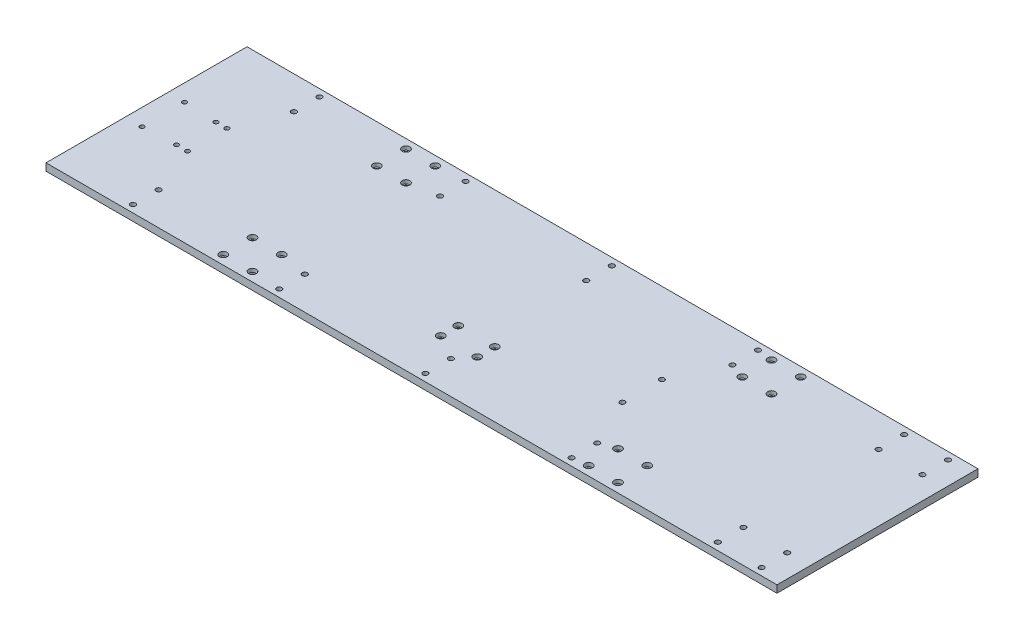
from build123d import *

# Parameters (mm, degrees)
SKETCH_1_W          = 1000
SKETCH_1_H          = 275
SKETCH_1_R          = 3
SKETCH_1_R_2        = 3.5
SKETCH_1_R_3        = 3.2
EXTRUDE_1_DEPTH     = 10
SKETCH_1290_R       = 5.25
CUT_EXTRUDE_1_DEPTH = 5


with BuildPart() as part:
    # Эскиз1 → Бобышка-Вытянуть1 (new body)
    with BuildSketch(Plane(origin=(0, 0, 0), x_dir=(1, 0, 0), z_dir=(0, 1, 0))):
        with Locations((223.202614379, 6.290849673)):
            Rectangle(SKETCH_1_W, SKETCH_1_H)
        with Locations((-253.797385621, 35.290849673)):
            Circle(SKETCH_1_R, mode=Mode.SUBTRACT)
        with Locations((-208.797385621, 33.290849673)):
            Circle(SKETCH_1_R, mode=Mode.SUBTRACT)
        with Locations((-193.797385621, 33.290849673)):
            Circle(SKETCH_1_R, mode=Mode.SUBTRACT)
        with Locations((-167.797385621, 133.790849673)):
            Circle(SKETCH_1_R_2, mode=Mode.SUBTRACT)
        with Locations((32.202614379, 133.790849673)):
            Circle(SKETCH_1_R_2, mode=Mode.SUBTRACT)
        with Locations((232.202614379, 133.790849673)):
            Circle(SKETCH_1_R_2, mode=Mode.SUBTRACT)
        with Locations((432.202614379, 133.790849673)):
            Circle(SKETCH_1_R_2, mode=Mode.SUBTRACT)
        with Locations((632.202614379, 133.790849673)):
            Circle(SKETCH_1_R_2, mode=Mode.SUBTRACT)
        with Locations((692.202614379, 133.790849673)):
            Circle(SKETCH_1_R_2, mode=Mode.SUBTRACT)
        with Locations((692.202614379, 98.790849673)):
            Circle(SKETCH_1_R_2, mode=Mode.SUBTRACT)
        with Locations((632.202614379, 98.790849673)):
            Circle(SKETCH_1_R_2, mode=Mode.SUBTRACT)
        with Locations((432.202614379, 98.790849673)):
            Circle(SKETCH_1_R_2, mode=Mode.SUBTRACT)
        with Locations((232.202614379, 98.790849673)):
            Circle(SKETCH_1_R_2, mode=Mode.SUBTRACT)
        with Locations((32.202614379, 98.790849673)):
            Circle(SKETCH_1_R_2, mode=Mode.SUBTRACT)
        with Locations((-167.797385621, 98.790849673)):
            Circle(SKETCH_1_R_2, mode=Mode.SUBTRACT)
        with Locations((632.202614379, -86.209150327)):
            Circle(SKETCH_1_R_2, mode=Mode.SUBTRACT)
        with Locations((692.202614379, -86.209150327)):
            Circle(SKETCH_1_R_2, mode=Mode.SUBTRACT)
        with Locations((692.202614379, -121.209150327)):
            Circle(SKETCH_1_R_2, mode=Mode.SUBTRACT)
        with Locations((632.202614379, -121.209150327)):
            Circle(SKETCH_1_R_2, mode=Mode.SUBTRACT)
        with Locations((432.202614379, -86.209150327)):
            Circle(SKETCH_1_R_2, mode=Mode.SUBTRACT)
        with Locations((432.202614379, -121.209150327)):
            Circle(SKETCH_1_R_2, mode=Mode.SUBTRACT)
        with Locations((232.202614379, -86.209150327)):
            Circle(SKETCH_1_R_2, mode=Mode.SUBTRACT)
        with Locations((232.202614379, -121.209150327)):
            Circle(SKETCH_1_R_2, mode=Mode.SUBTRACT)
        with Locations((32.202614379, -86.209150327)):
            Circle(SKETCH_1_R_2, mode=Mode.SUBTRACT)
        with Locations((32.202614379, -121.209150327)):
            Circle(SKETCH_1_R_2, mode=Mode.SUBTRACT)
        with Locations((-167.797385621, -86.209150327)):
            Circle(SKETCH_1_R_2, mode=Mode.SUBTRACT)
        with Locations((-167.797385621, -121.209150327)):
            Circle(SKETCH_1_R_2, mode=Mode.SUBTRACT)
        with Locations((401.202614379, 33.290849673)):
            Circle(SKETCH_1_R_2, mode=Mode.SUBTRACT)
        with Locations((401.202614379, -20.709150327)):
            Circle(SKETCH_1_R_2, mode=Mode.SUBTRACT)
        with Locations((-193.797385621, -20.709150327)):
            Circle(SKETCH_1_R, mode=Mode.SUBTRACT)
        with Locations((-208.797385621, -20.709150327)):
            Circle(SKETCH_1_R, mode=Mode.SUBTRACT)
        with Locations((-253.797385621, -22.709150327)):
            Circle(SKETCH_1_R, mode=Mode.SUBTRACT)
        with Locations((-46.797385621, -118.709150327)):
            Circle(SKETCH_1_R_3, mode=Mode.SUBTRACT)
        with Locations((-46.797385621, -78.709150327)):
            Circle(SKETCH_1_R_3, mode=Mode.SUBTRACT)
        with Locations((-6.797385621, -78.709150327)):
            Circle(SKETCH_1_R_3, mode=Mode.SUBTRACT)
        with Locations((-6.797385621, -118.709150327)):
            Circle(SKETCH_1_R_3, mode=Mode.SUBTRACT)
        with Locations((-6.797385621, 131.290849673)):
            Circle(SKETCH_1_R_3, mode=Mode.SUBTRACT)
        with Locations((-46.797385621, 131.290849673)):
            Circle(SKETCH_1_R_3, mode=Mode.SUBTRACT)
        with Locations((-6.797385621, 91.290849673)):
            Circle(SKETCH_1_R_3, mode=Mode.SUBTRACT)
        with Locations((-46.797385621, 91.290849673)):
            Circle(SKETCH_1_R_3, mode=Mode.SUBTRACT)
        with Locations((493.202614379, -118.709150327)):
            Circle(SKETCH_1_R_3, mode=Mode.SUBTRACT)
        with Locations((493.202614379, -78.709150327)):
            Circle(SKETCH_1_R_3, mode=Mode.SUBTRACT)
        with Locations((453.202614379, -118.709150327)):
            Circle(SKETCH_1_R_3, mode=Mode.SUBTRACT)
        with Locations((453.202614379, -78.709150327)):
            Circle(SKETCH_1_R_3, mode=Mode.SUBTRACT)
        with Locations((493.202614379, 131.290849673)):
            Circle(SKETCH_1_R_3, mode=Mode.SUBTRACT)
        with Locations((453.202614379, 131.290849673)):
            Circle(SKETCH_1_R_3, mode=Mode.SUBTRACT)
        with Locations((493.202614379, 91.290849673)):
            Circle(SKETCH_1_R_3, mode=Mode.SUBTRACT)
        with Locations((453.202614379, 91.290849673)):
            Circle(SKETCH_1_R_3, mode=Mode.SUBTRACT)
        with Locations((198.202614379, -66.209150327)):
            Circle(SKETCH_1_R_3, mode=Mode.SUBTRACT)
        with Locations((198.202614379, -42.209150327)):
            Circle(SKETCH_1_R_3, mode=Mode.SUBTRACT)
        with Locations((248.202614379, -66.209150327)):
            Circle(SKETCH_1_R_3, mode=Mode.SUBTRACT)
        with Locations((248.202614379, -42.209150327)):
            Circle(SKETCH_1_R_3, mode=Mode.SUBTRACT)
    extrude(amount=EXTRUDE_1_DEPTH)

    # Sketch 1290 → Вырез-Вытянуть1 (cut)
    with BuildSketch(Plane(origin=(0, 10, -10), x_dir=(1, 0, 0), z_dir=(0, -1, 0))):
        with Locations((-46.797385621, -121.290849673)):
            Circle(SKETCH_1290_R)
        with Locations((-46.797385621, -81.290849673)):
            Circle(SKETCH_1290_R)
        with Locations((-6.797385621, -81.290849673)):
            Circle(SKETCH_1290_R)
        with Locations((-6.797385621, -121.290849673)):
            Circle(SKETCH_1290_R)
        with Locations((-6.797385621, 128.709150327)):
            Circle(SKETCH_1290_R)
        with Locations((-46.797385621, 128.709150327)):
            Circle(SKETCH_1290_R)
        with Locations((-6.797385621, 88.709150327)):
            Circle(SKETCH_1290_R)
        with Locations((-46.797385621, 88.709150327)):
            Circle(SKETCH_1290_R)
        with Locations((493.202614379, -121.290849673)):
            Circle(SKETCH_1290_R)
        with Locations((493.202614379, -81.290849673)):
            Circle(SKETCH_1290_R)
        with Locations((453.202614379, -121.290849673)):
            Circle(SKETCH_1290_R)
        with Locations((453.202614379, -81.290849673)):
            Circle(SKETCH_1290_R)
        with Locations((493.202614379, 128.709150327)):
            Circle(SKETCH_1290_R)
        with Locations((453.202614379, 128.709150327)):
            Circle(SKETCH_1290_R)
        with Locations((493.202614379, 88.709150327)):
            Circle(SKETCH_1290_R)
        with Locations((453.202614379, 88.709150327)):
            Circle(SKETCH_1290_R)
        with Locations((198.202614379, 52.209150327)):
            Circle(SKETCH_1290_R)
        with Locations((198.202614379, 76.209150327)):
            Circle(SKETCH_1290_R)
        with Locations((248.202614379, 76.209150327)):
            Circle(SKETCH_1290_R)
        with Locations((248.202614379, 52.209150327)):
            Circle(SKETCH_1290_R)
    extrude(amount=CUT_EXTRUDE_1_DEPTH, mode=Mode.SUBTRACT)


solid = part.part
